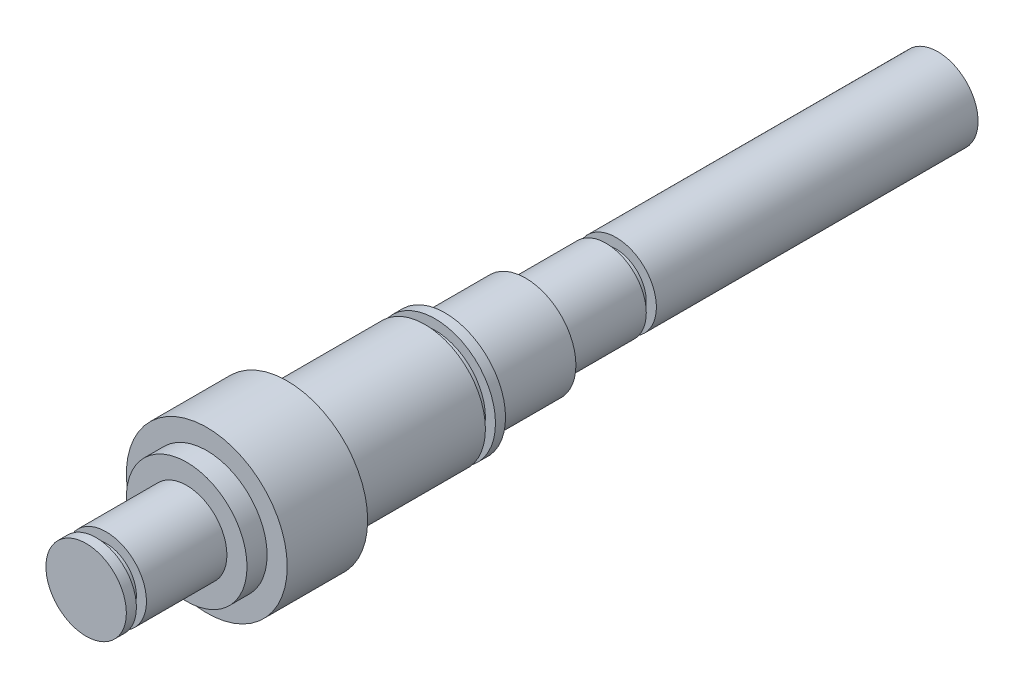
from build123d import *

# Parameters (mm, degrees)
SKETCH2_R            = 12.7
BOSS_EXTRUDE1_DEPTH  = 25.4
SKETCH3_R            = 15.875
BOSS_EXTRUDE2_DEPTH  = 25.4
SKETCH4_R            = 19.05
BOSS_EXTRUDE3_DEPTH  = 3.175
SKETCH5_R            = 15.875
BOSS_EXTRUDE4_DEPTH  = 3.175
SKETCH6_R            = 19.05
BOSS_EXTRUDE5_DEPTH  = 43.5356
SKETCH7_R            = 25.4
BOSS_EXTRUDE6_DEPTH  = 25.4
SKETCH8_R            = 19.05
BOSS_EXTRUDE7_DEPTH  = 6.35
SKETCH9_R            = 12.7
BOSS_EXTRUDE8_DEPTH  = 25.4
CUT_EXTRUDE1_DEPTH   = 3.175
SKETCH11_R           = 9.525
BOSS_EXTRUDE9_DEPTH  = 3.175
SKETCH12_R           = 12.7
BOSS_EXTRUDE10_DEPTH = 101.6
SKETCH13_R           = 9.525
BOSS_EXTRUDE11_DEPTH = 3.175
SKETCH14_R           = 12.7
BOSS_EXTRUDE12_DEPTH = 3.175


with BuildPart() as part:
    # Sketch2 → Boss-Extrude1 (new body)
    with BuildSketch(Plane.XY):
        Circle(SKETCH2_R)
    extrude(amount=BOSS_EXTRUDE1_DEPTH)

    # Sketch3 → Boss-Extrude2 (add)
    with BuildSketch(Plane.XY.offset(25.4)):
        Circle(SKETCH3_R)
    extrude(amount=BOSS_EXTRUDE2_DEPTH)

    # Sketch4 → Boss-Extrude3 (add)
    with BuildSketch(Plane.XY.offset(50.8)):
        Circle(SKETCH4_R)
    extrude(amount=BOSS_EXTRUDE3_DEPTH)

    # Sketch5 → Boss-Extrude4 (add)
    with BuildSketch(Plane.XY.offset(53.975)):
        Circle(SKETCH5_R)
    extrude(amount=BOSS_EXTRUDE4_DEPTH)

    # Sketch6 → Boss-Extrude5 (add)
    with BuildSketch(Plane.XY.offset(57.15)):
        Circle(SKETCH6_R)
    extrude(amount=BOSS_EXTRUDE5_DEPTH)

    # Sketch7 → Boss-Extrude6 (add)
    with BuildSketch(Plane.XY.offset(100.6856)):
        Circle(SKETCH7_R)
    extrude(amount=BOSS_EXTRUDE6_DEPTH)

    # Sketch8 → Boss-Extrude7 (add)
    with BuildSketch(Plane.XY.offset(126.0856)):
        Circle(SKETCH8_R)
    extrude(amount=BOSS_EXTRUDE7_DEPTH)

    # Sketch9 → Boss-Extrude8 (add)
    with BuildSketch(Plane.XY.offset(132.4356)):
        Circle(SKETCH9_R)
    extrude(amount=BOSS_EXTRUDE8_DEPTH)

    # Sketch10 → Cut-Extrude1 (cut)
    with BuildSketch(Plane(origin=(0, -19.05, 0), x_dir=(-1, 0, 0), z_dir=(0, -1, 0))):
        with BuildLine():
            Line((3.175, -69.3928), (3.175, -88.4428))
            ThreePointArc((3.175, -88.4428), (0, -91.6178), (-3.175, -88.4428))
            Line((-3.175, -88.4428), (-3.175, -69.3928))
            ThreePointArc((-3.175, -69.3928), (0, -66.2178), (3.175, -69.3928))
        make_face()
    extrude(amount=-CUT_EXTRUDE1_DEPTH, mode=Mode.SUBTRACT)

    # Sketch11 → Boss-Extrude9 (add)
    with BuildSketch(Plane(origin=(0, 0, 0), x_dir=(-1, 0, 0), z_dir=(0, 0, -1))):
        Circle(SKETCH11_R)
    extrude(amount=BOSS_EXTRUDE9_DEPTH)

    # Sketch12 → Boss-Extrude10 (add)
    with BuildSketch(Plane(origin=(0, 0, -3.175), x_dir=(-1, 0, 0), z_dir=(0, 0, -1))):
        Circle(SKETCH12_R)
    extrude(amount=BOSS_EXTRUDE10_DEPTH)

    # Sketch13 → Boss-Extrude11 (add)
    with BuildSketch(Plane.XY.offset(157.8356)):
        Circle(SKETCH13_R)
    extrude(amount=BOSS_EXTRUDE11_DEPTH)

    # Sketch14 → Boss-Extrude12 (add)
    with BuildSketch(Plane.XY.offset(161.0106)):
        Circle(SKETCH14_R)
    extrude(amount=BOSS_EXTRUDE12_DEPTH)


solid = part.part
